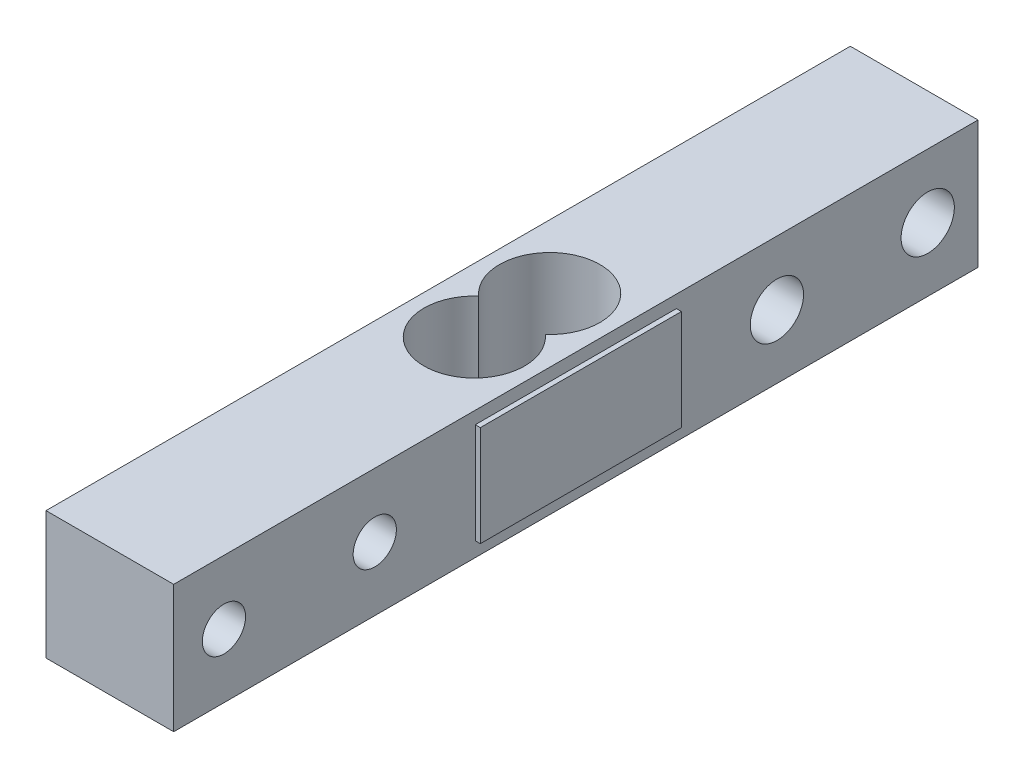
from build123d import *

# Parameters (mm, degrees)
SKETCH1_W           = 80
SKETCH1_H           = 12.7
BOSS_EXTRUDE1_DEPTH = 12.7
SKETCH2_R           = 5
CUT_EXTRUDE1_DEPTH  = 13.7
SKETCH3_R           = 2.15
SKETCH3_R_2         = 2.65
CUT_EXTRUDE2_DEPTH  = 13.7
BOSS_EXTRUDE2_START = -1.25
SKETCH4_W           = 0.5
SKETCH4_H           = 20
BOSS_EXTRUDE2_DEPTH = 10


with BuildPart() as part:
    # Sketch1 → Boss-Extrude1 (new body)
    with BuildSketch(Plane(origin=(0, 0, 0), x_dir=(0, 0, -1), z_dir=(1, 0, 0))):
        Rectangle(SKETCH1_W, SKETCH1_H)
    extrude(amount=BOSS_EXTRUDE1_DEPTH)

    # Sketch2 → Cut-Extrude1 (cut, through all)
    with BuildSketch(Plane(origin=(0, 6.35, 0), x_dir=(1, 0, 0), z_dir=(0, 1, 0))):
        with Locations((6.35, -3.75)):
            Circle(SKETCH2_R)
        with Locations((6.35, 3.75)):
            Circle(SKETCH2_R)
    extrude(amount=-CUT_EXTRUDE1_DEPTH, mode=Mode.SUBTRACT)

    # Sketch3 → Cut-Extrude2 (cut, through all)
    with BuildSketch(Plane(origin=(12.7, 0, 0), x_dir=(0, 0, -1), z_dir=(1, 0, 0))):
        with Locations((-35, 0)):
            Circle(SKETCH3_R)
        with Locations((-20, 0)):
            Circle(SKETCH3_R)
        with Locations((20, 0)):
            Circle(SKETCH3_R_2)
        with Locations((35, 0)):
            Circle(SKETCH3_R_2)
    extrude(amount=-CUT_EXTRUDE2_DEPTH, mode=Mode.SUBTRACT)

    # Sketch4 → Boss-Extrude2 (add)
    with BuildSketch(Plane(origin=(0, 6.35, 0), x_dir=(1, 0, 0), z_dir=(0, 1, 0)).offset(BOSS_EXTRUDE2_START)):
        with Locations((-0.25, 0)):
            Rectangle(SKETCH4_W, SKETCH4_H)
        with Locations((12.95, 0)):
            Rectangle(SKETCH4_W, SKETCH4_H)
    extrude(amount=-BOSS_EXTRUDE2_DEPTH)


solid = part.part
